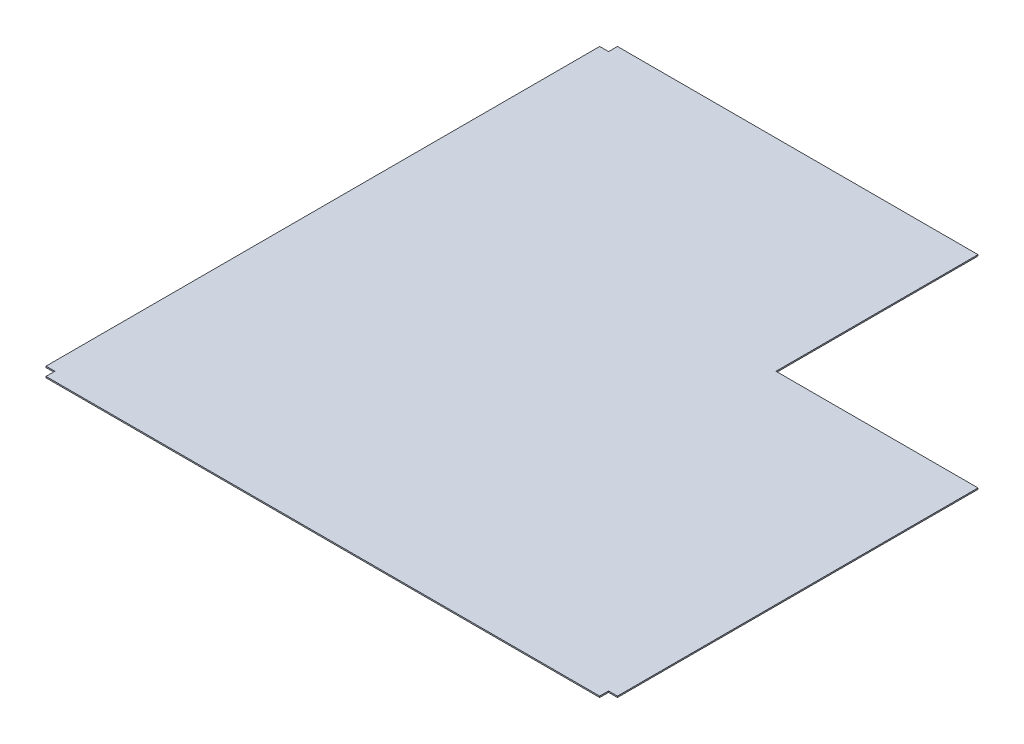
from build123d import *

# Parameters (mm, degrees)
EXTRUDE_1_DEPTH = 1


with BuildPart() as part:
    # 스케치1 → 보스-돌출1 (new body)
    with BuildSketch(Plane(origin=(0, 0, 0), x_dir=(1, 0, 0), z_dir=(0, 1, 0))):
        Polygon((0, 0), (0, -6.9), (-6.9, -6.9), (-6.9, -436.9), (0, -436.9), (0, -443.8), (430, -443.8), (430, -436.9), (436.9, -436.9), (436.9, -156.9), (280, -156.9), (280, 0), align=None)
    extrude(amount=EXTRUDE_1_DEPTH)


solid = part.part
